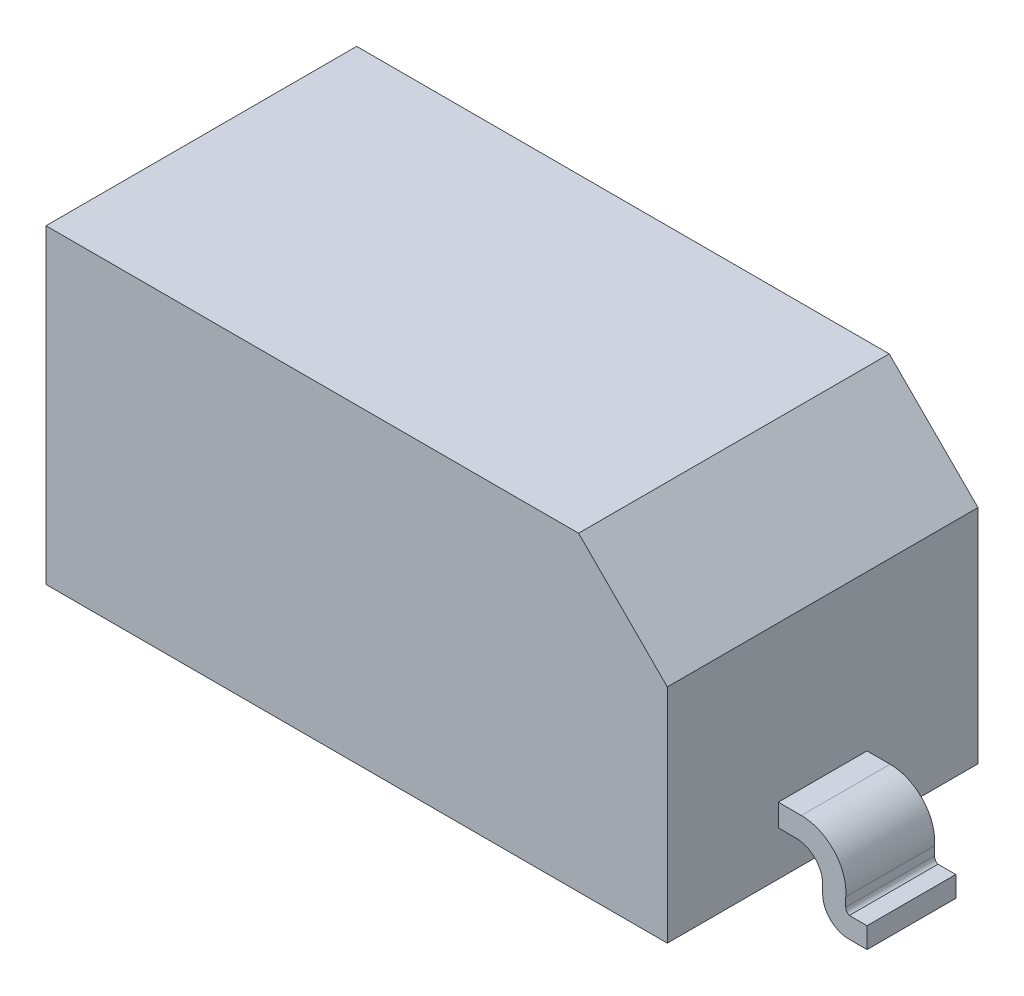
from build123d import *

# Parameters (mm, degrees)
EXTRUDE1_DEPTH = 0.875
EXTRUDE2_DEPTH = 0.25


with BuildPart() as part:
    # Sketch1 → Extrude1 (new body, symmetric)
    with BuildSketch(Plane.XY):
        Polygon((-1.75, -0.875), (1.75, -0.875), (1.75, 0.375), (1.25, 0.875), (-1.75, 0.875), align=None)
    extrude(amount=EXTRUDE1_DEPTH, both=True)

    # Sketch2 → Extrude2 (add, symmetric)
    with BuildSketch(Plane.XY):
        with BuildLine():
            Line((1.75, -0.625), (1.85, -0.625))
            ThreePointArc((1.85, -0.625), (1.955, -0.66786607), (2, -0.771969385))
            Line((2, -0.771969385), (2, -0.821969385))
            ThreePointArc((2, -0.821969385), (2.044121431, -0.926969385), (2.15, -0.968938769))
            Line((2.15, -0.968938769), (2.25, -0.968938769))
            Line((2.25, -0.968938769), (2.25, -0.852248548))
            Line((2.25, -0.852248548), (2.15, -0.852248548))
            ThreePointArc((2.15, -0.852248548), (2.135458365, -0.840276305), (2.13, -0.822248548))
            Line((2.13, -0.822248548), (2.13, -0.772248548))
            ThreePointArc((2.13, -0.772248548), (2.065, -0.580874063), (1.88, -0.499484914))
            Line((1.88, -0.499484914), (1.75, -0.499484914))
            Line((1.75, -0.499484914), (1.75, -0.625))
        make_face()
    extrude2 = extrude(amount=EXTRUDE2_DEPTH, both=True)

    # Mirror1: Extrude2 across plane
    add(extrude2.mirror(Plane(origin=(0, 0, 0), x_dir=(0, 0, 1), z_dir=(1, 0, 0))))


solid = part.part
